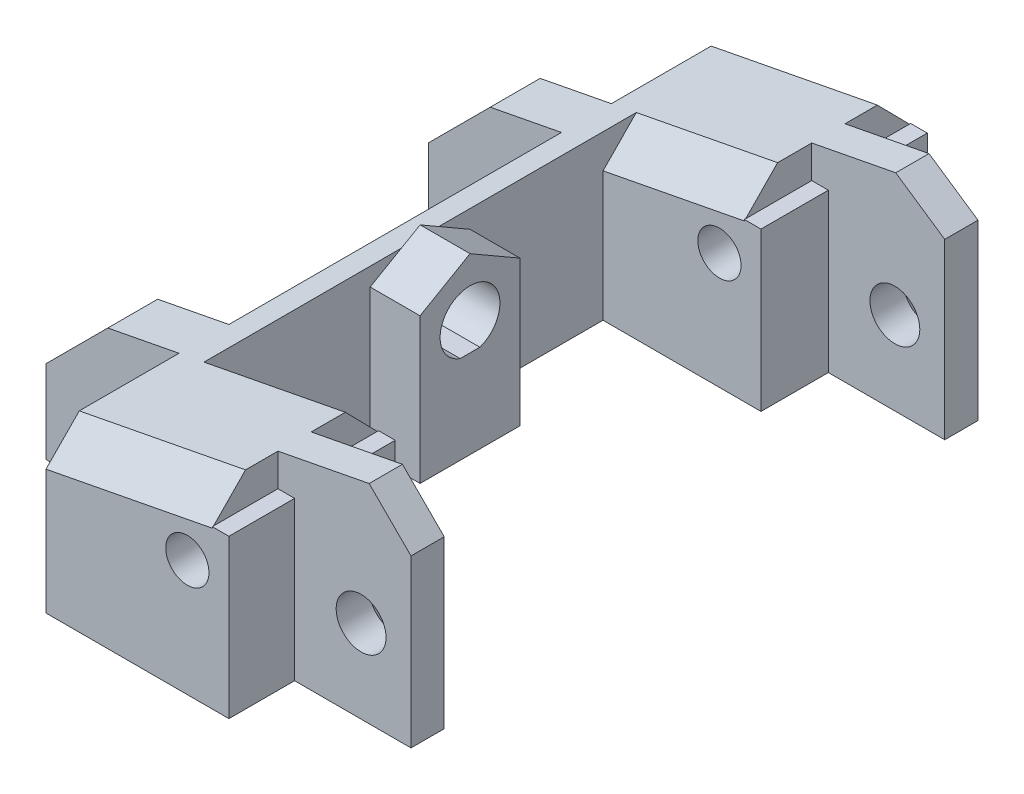
from build123d import *

# Parameters (mm, degrees)
EXTRUDE_1_DEPTH        = 13
SKETCH_2_R             = 1.5
SKETCH_2_R_2           = 1.3
CUT_EXTRUDE_1_DEPTH    = 43
CHAMFER_1_SIZE2        = 3
CHAMFER_1_SIZE         = 3.784471042
CHAMFER_1_EDGE_2_SIZE2 = 3
CHAMFER_1_EDGE_2_SIZE  = 3.784471042
CHAMFER_1_EDGE_3_SIZE2 = 3
CHAMFER_1_EDGE_3_SIZE  = 2.56157214
CHAMFER_1_EDGE_4_SIZE2 = 2.56157214
CHAMFER_1_EDGE_4_SIZE  = 3
CHAMFER_2_SIZE         = 2
SKETCH_5_R             = 1.8
EXTRUDE_2_DEPTH        = 3
SKETCH_6_R             = 1.8
CUT_EXTRUDE_2_DEPTH    = 3
SKETCH_7_W             = 3
SKETCH_7_H             = 6.007931748
EXTRUDE_3_DEPTH        = 5.3
SKETCH_8_W             = 1
SKETCH_8_H             = 10
EXTRUDE_4_DEPTH        = 9.5


with BuildPart() as part:
    # 草图1 → 凸台-拉伸1 (new body)
    with BuildSketch(Plane(origin=(0, 0, 0), x_dir=(1, 0, 0), z_dir=(0, 1, 0))):
        Polygon((13, -15.05), (5, -15.05), (5, -11), (-3.5, -11), (-3.5, 11), (5, 11), (5, 15.05), (13, 15.05), (13, 17.05), (5, 17.05), (5, 21), (-5, 21), (-5, 13), (-13, 13), (-13, 10), (-5, 10), (-5, -10), (-13, -10), (-13, -13), (-5, -13), (-5, -21), (5, -21), (5, -17.05), (13, -17.05), align=None)
    extrude(amount=EXTRUDE_1_DEPTH)

    # 草图2 → 切除-拉伸1 (cut, through all)
    with BuildSketch(Plane.XY.offset(21)):
        with Locations((10, 5)):
            Circle(SKETCH_2_R)
        with Locations((-8, 2.5)):
            Circle(SKETCH_2_R)
        with Locations((3.5, 7)):
            Circle(SKETCH_2_R_2)
        Polygon((-13, 7.989732885), (13, 13), (-13, 13), align=None)
    extrude(amount=-CUT_EXTRUDE_1_DEPTH, mode=Mode.SUBTRACT)

    # 倒角1
    chamfer_1_edges = [part.edges().sort_by_distance(p)[0] for p in [
        (-13, 7.989732885, -11.5),
    ]]
    chamfer(chamfer_1_edges, length=CHAMFER_1_SIZE, length2=CHAMFER_1_SIZE2)

    # 倒角1 edge 2
    chamfer_1_edge_2_edges = [part.edges().sort_by_distance(p)[0] for p in [
        (-13, 7.989732885, 11.5),
    ]]
    chamfer(chamfer_1_edge_2_edges, length=CHAMFER_1_EDGE_2_SIZE, length2=CHAMFER_1_EDGE_2_SIZE2)

    # 倒角1 edge 3
    chamfer_1_edge_3_edges = [part.edges().sort_by_distance(p)[0] for p in [
        (13, 13, 16.05),
    ]]
    chamfer(chamfer_1_edge_3_edges, length=CHAMFER_1_EDGE_3_SIZE, length2=CHAMFER_1_EDGE_3_SIZE2)

    # 倒角1 edge 4
    chamfer_1_edge_4_edges = [part.edges().sort_by_distance(p)[0] for p in [
        (13, 13, -16.05),
    ]]
    chamfer(chamfer_1_edge_4_edges, length=CHAMFER_1_EDGE_4_SIZE, length2=CHAMFER_1_EDGE_4_SIZE2)

    # 倒角2
    chamfer_2_edges = [part.edges().sort_by_distance(p)[0] for p in [
        (0, 10.494866442, -21),
        (0.75, 10.639393378, 11),
        (0.75, 10.639393378, -11),
        (0, 10.494866442, 21),
    ]]
    chamfer(chamfer_2_edges, length=CHAMFER_2_SIZE)

    # 草图5 → 凸台-拉伸2 (add)
    with BuildSketch(Plane(origin=(-3.5, 0, 0), x_dir=(0, 0, -1), z_dir=(1, 0, 0))):
        Polygon((0, 10.468681012), (-3.003965874, 8.734340506), (-3.003965874, 5.265659494), (0, 3.531318988), (3.003965874, 5.265659494), (3.003965874, 8.734340506), align=None)
        with Locations((0, 7)):
            Circle(SKETCH_5_R, mode=Mode.SUBTRACT)
    extrude(amount=EXTRUDE_2_DEPTH)

    # 草图6 → 切除-拉伸2 (cut)
    with BuildSketch(Plane(origin=(-3.5, 0, 0), x_dir=(0, 0, -1), z_dir=(1, 0, 0))):
        with Locations((0, 7)):
            Circle(SKETCH_6_R)
    extrude(amount=-CUT_EXTRUDE_2_DEPTH, mode=Mode.SUBTRACT)

    # 草图7 → 凸台-拉伸3 (add)
    with BuildSketch(Plane.XZ):
        with Locations((-2, 0)):
            Rectangle(SKETCH_7_W, SKETCH_7_H)
    extrude(amount=-EXTRUDE_3_DEPTH)

    # 草图8 → 凸台-拉伸4 (add)
    with BuildSketch(Plane.XZ):
        with Locations((5.5, 16)):
            Rectangle(SKETCH_8_W, SKETCH_8_H)
        with Locations((5.5, -16)):
            Rectangle(SKETCH_8_W, SKETCH_8_H)
    extrude(amount=-EXTRUDE_4_DEPTH)


solid = part.part
